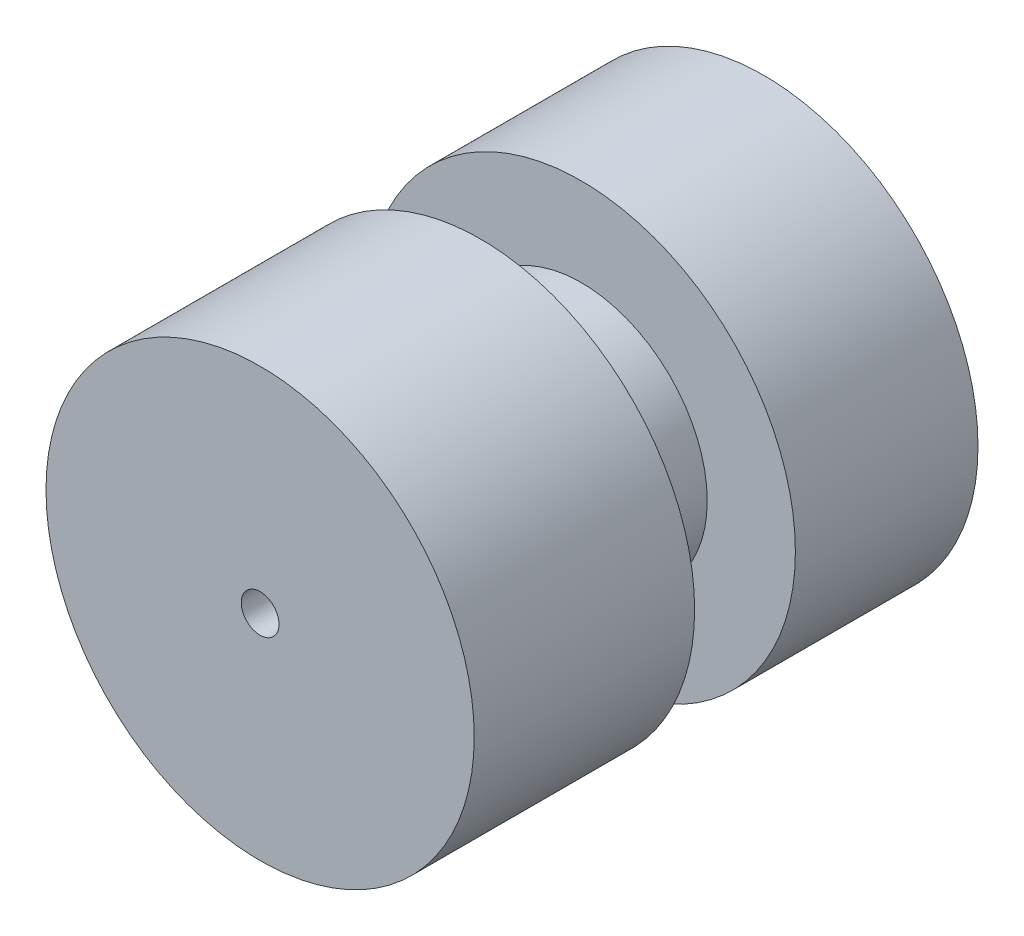
from build123d import *

# Parameters (mm, degrees)
SKETCH1_R           = 17
SKETCH1_R_2         = 1.5
BOSS_EXTRUDE1_DEPTH = 40
CUT_EXTRUDE1_START  = -17.5
SKETCH2_R           = 17
SKETCH2_R_2         = 10
CUT_EXTRUDE1_DEPTH  = 8


with BuildPart() as part:
    # Sketch1 → Boss-Extrude1 (new body)
    with BuildSketch(Plane.XY):
        Circle(SKETCH1_R)
        Circle(SKETCH1_R_2, mode=Mode.SUBTRACT)
    extrude(amount=BOSS_EXTRUDE1_DEPTH)

    # Sketch2 → Cut-Extrude1 (cut)
    with BuildSketch(Plane.XY.offset(40).offset(CUT_EXTRUDE1_START)):
        Circle(SKETCH2_R)
        Circle(SKETCH2_R_2, mode=Mode.SUBTRACT)
    extrude(amount=-CUT_EXTRUDE1_DEPTH, mode=Mode.SUBTRACT)


solid = part.part
